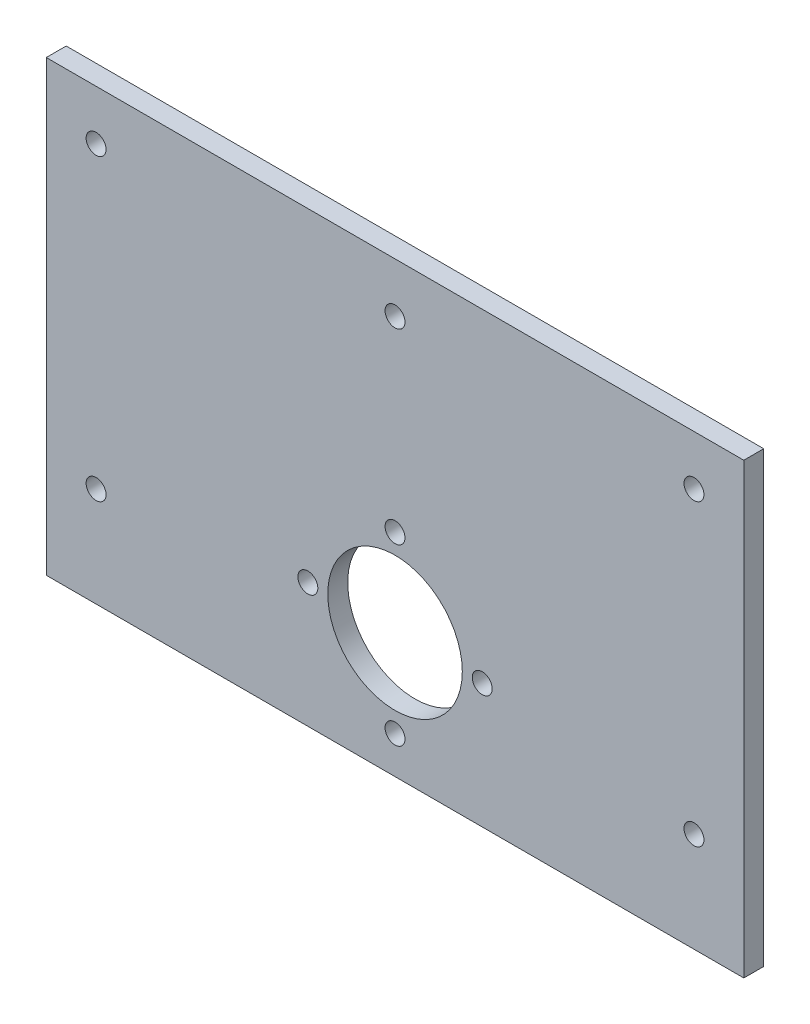
from build123d import *

# Parameters (mm, degrees)
SKETCH1_W           = 140
SKETCH1_H           = 90
SKETCH1_R           = 2
SKETCH1_R_2         = 13.5
BOSS_EXTRUDE1_DEPTH = 4
SKETCH2_R           = 2
CUT_EXTRUDE1_DEPTH  = 5
SKETCH3_R           = 2
CUT_EXTRUDE2_DEPTH  = 5


with BuildPart() as part:
    # Sketch1 → Boss-Extrude1 (new body)
    with BuildSketch(Plane.XY):
        Rectangle(SKETCH1_W, SKETCH1_H)
        with Locations((0, -2.5)):
            Circle(SKETCH1_R, mode=Mode.SUBTRACT)
        with Locations((17.5, -20)):
            Circle(SKETCH1_R, mode=Mode.SUBTRACT)
        with Locations((0, -37.5)):
            Circle(SKETCH1_R, mode=Mode.SUBTRACT)
        with Locations((-17.5, -20)):
            Circle(SKETCH1_R, mode=Mode.SUBTRACT)
        with Locations((0, -20)):
            Circle(SKETCH1_R_2, mode=Mode.SUBTRACT)
    extrude(amount=BOSS_EXTRUDE1_DEPTH)

    # Sketch2 → Cut-Extrude1 (cut, through all)
    with BuildSketch(Plane.XY.offset(4)):
        with Locations((0, 35)):
            Circle(SKETCH2_R)
        with Locations((-60, 35)):
            Circle(SKETCH2_R)
        with Locations((60, 35)):
            Circle(SKETCH2_R)
    extrude(amount=-CUT_EXTRUDE1_DEPTH, mode=Mode.SUBTRACT)

    # Sketch3 → Cut-Extrude2 (cut, through all)
    with BuildSketch(Plane.XY.offset(4)):
        with Locations((-60, -25)):
            Circle(SKETCH3_R)
        with Locations((-60, -85)):
            Circle(SKETCH3_R)
        with Locations((60, -85)):
            Circle(SKETCH3_R)
        with Locations((60, -25)):
            Circle(SKETCH3_R)
    extrude(amount=-CUT_EXTRUDE2_DEPTH, mode=Mode.SUBTRACT)


solid = part.part
